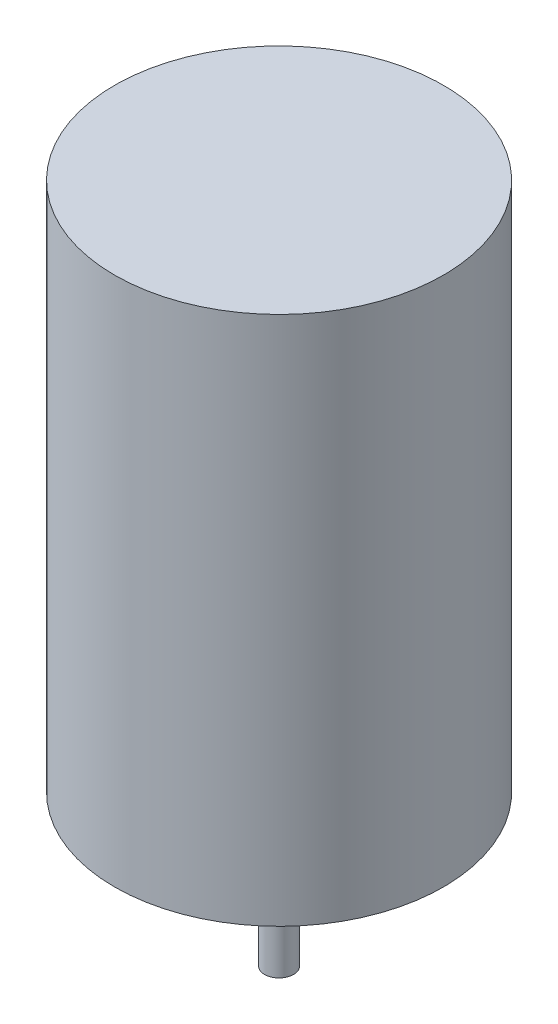
from build123d import *

# Parameters (mm, degrees)
SKETCH1_R           = 18
BOSS_EXTRUDE1_DEPTH = 58
SKETCH2_R           = 1.5875
BOSS_EXTRUDE2_DEPTH = 16.5
SKETCH3_R           = 1.5
CUT_EXTRUDE1_DEPTH  = 5
SKETCH3_3_R         = 6.5
SKETCH3_3_R_2       = 1.5875
BOSS_EXTRUDE3_DEPTH = 4.5


with BuildPart() as part:
    # Sketch1 → Boss-Extrude1 (new body)
    with BuildSketch(Plane(origin=(0, 0, 0), x_dir=(1, 0, 0), z_dir=(0, 1, 0))):
        Circle(SKETCH1_R)
    extrude(amount=BOSS_EXTRUDE1_DEPTH)

    # Sketch2 → Boss-Extrude2 (add)
    with BuildSketch(Plane.XZ):
        Circle(SKETCH2_R)
    extrude(amount=BOSS_EXTRUDE2_DEPTH)

    # Sketch3 → Cut-Extrude1 (cut)
    with BuildSketch(Plane(origin=(0, 0, 0), x_dir=(-1, 0, 0), z_dir=(0, -1, 0))):
        with Locations((-12.5, 0)):
            Circle(SKETCH3_R)
        with Locations((12.5, 0)):
            Circle(SKETCH3_R)
    extrude(amount=-CUT_EXTRUDE1_DEPTH, mode=Mode.SUBTRACT)

    # Sketch3_3 → Boss-Extrude3 (add)
    with BuildSketch(Plane(origin=(0, 0, 0), x_dir=(-1, 0, 0), z_dir=(0, -1, 0))):
        Circle(SKETCH3_3_R)
        Circle(SKETCH3_3_R_2, mode=Mode.SUBTRACT)
    extrude(amount=BOSS_EXTRUDE3_DEPTH)


solid = part.part
